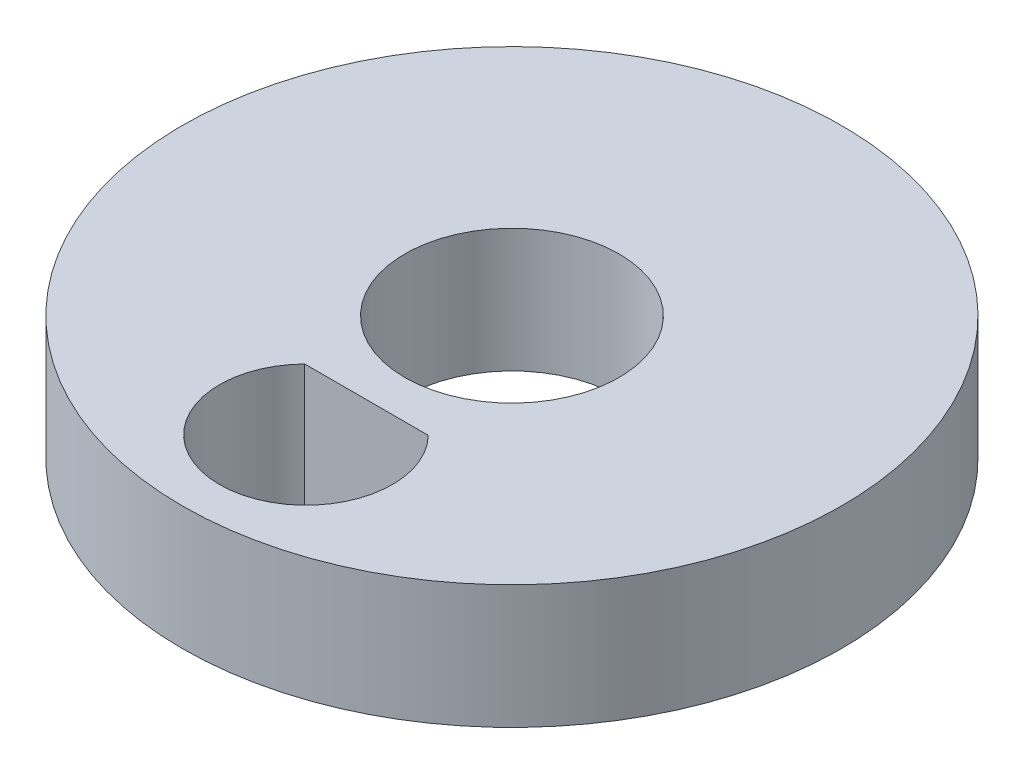
from build123d import *

# Parameters (mm, degrees)
SKETCH1_R           = 8
SKETCH1_R_2         = 2.6
BOSS_EXTRUDE1_DEPTH = 3


with BuildPart() as part:
    # Sketch1 → Boss-Extrude1 (new body)
    with BuildSketch(Plane(origin=(0, 0, 0), x_dir=(1, 0, 0), z_dir=(0, 1, 0))):
        Circle(SKETCH1_R)
        Circle(SKETCH1_R_2, mode=Mode.SUBTRACT)
        with BuildLine():
            Line((1.5, -3.530306154), (-1.5, -3.530306154))
            ThreePointArc((-1.5, -3.530306154), (0, -7.1), (1.5, -3.530306154))
        make_face(mode=Mode.SUBTRACT)
    extrude(amount=BOSS_EXTRUDE1_DEPTH)


solid = part.part
